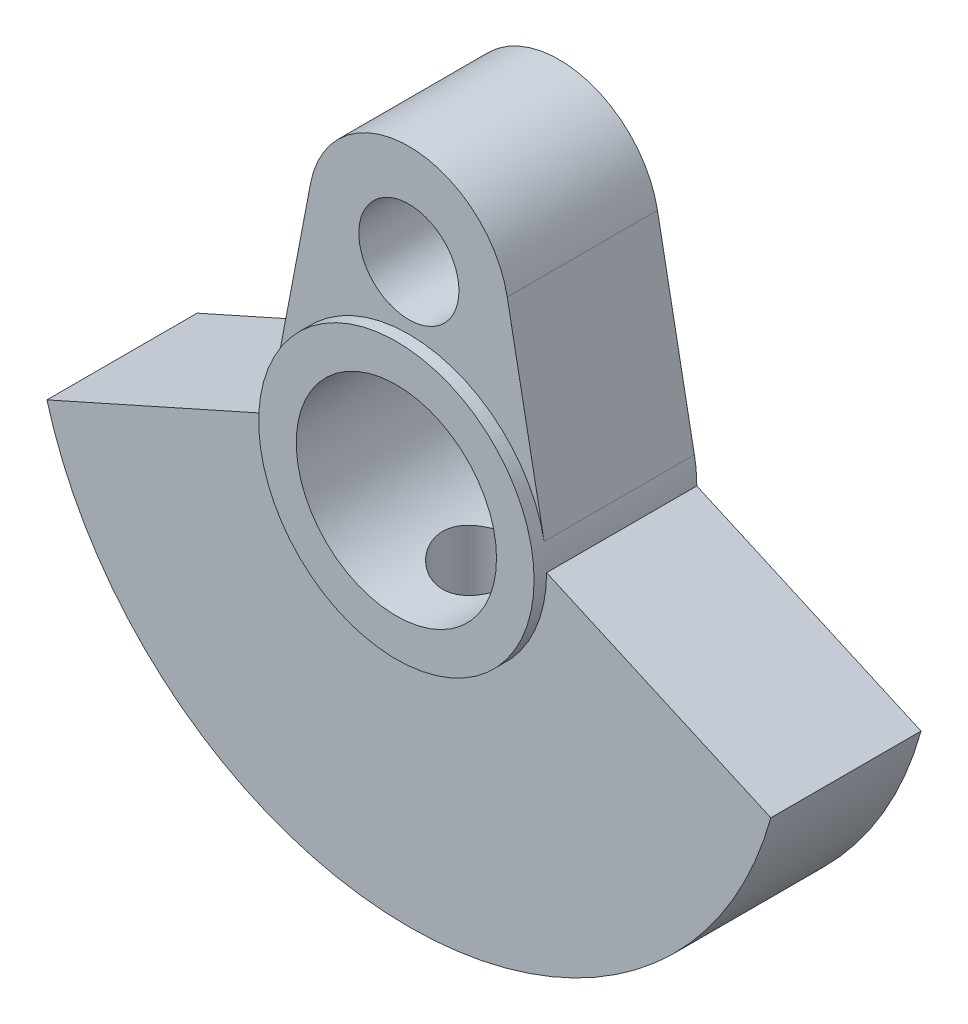
from build123d import *

# Parameters (mm, degrees)
SKETCH1_R           = 2
BOSS_EXTRUDE1_DEPTH = 3
SKETCH2_R           = 5.5
SKETCH2_R_2         = 4
BOSS_EXTRUDE2_DEPTH = 0.5
SKETCH4_R           = 4
CUT_EXTRUDE2_DEPTH  = 7


with BuildPart() as part:
    # Sketch1 → Boss-Extrude1 (new body, symmetric)
    with BuildSketch(Plane.XY):
        with BuildLine():
            Line((-5.5, 0), (-14.456832295, -4))
            ThreePointArc((-14.456832295, -4), (0, -15), (14.456832295, -4))
            Line((14.456832295, -4), (5.5, 0))
            ThreePointArc((5.5, 0), (5.475559526, 0.517926522), (5.402455316, 1.03125))
            Line((5.402455316, 1.03125), (3.929058411, 8.75))
            ThreePointArc((3.929058411, 8.75), (0, 12), (-3.929058411, 8.75))
            Line((-3.929058411, 8.75), (-5.402455316, 1.03125))
            ThreePointArc((-5.402455316, 1.03125), (-5.475559526, 0.517926522), (-5.5, 0))
        make_face()
        with Locations((0, 8)):
            Circle(SKETCH1_R, mode=Mode.SUBTRACT)
    extrude(amount=BOSS_EXTRUDE1_DEPTH, both=True)

    # Sketch2 → Boss-Extrude2 (add)
    with BuildSketch(Plane.XY.offset(3)):
        Circle(SKETCH2_R)
        Circle(SKETCH2_R_2, mode=Mode.SUBTRACT)
    extrude(amount=BOSS_EXTRUDE2_DEPTH)

    # Sketch4 → Cut-Extrude2 (cut, through all)
    with BuildSketch(Plane.XY.offset(3)):
        Circle(SKETCH4_R)
    extrude(amount=-CUT_EXTRUDE2_DEPTH, mode=Mode.SUBTRACT)

    # Sketch8 → M4 Tapped Hole1 (revolve, cut)
    with BuildSketch(Plane(origin=(0, 0, 0), x_dir=(0, 0, 1), z_dir=(1, 0, 0))):
        Polygon((0, 0), (0, 22.491420021), (1.65, 21.5), (1.65, 0), align=None)
    revolve(axis=Axis((0, 6.35, 0), (0, -1, 0)), mode=Mode.SUBTRACT)


solid = part.part
